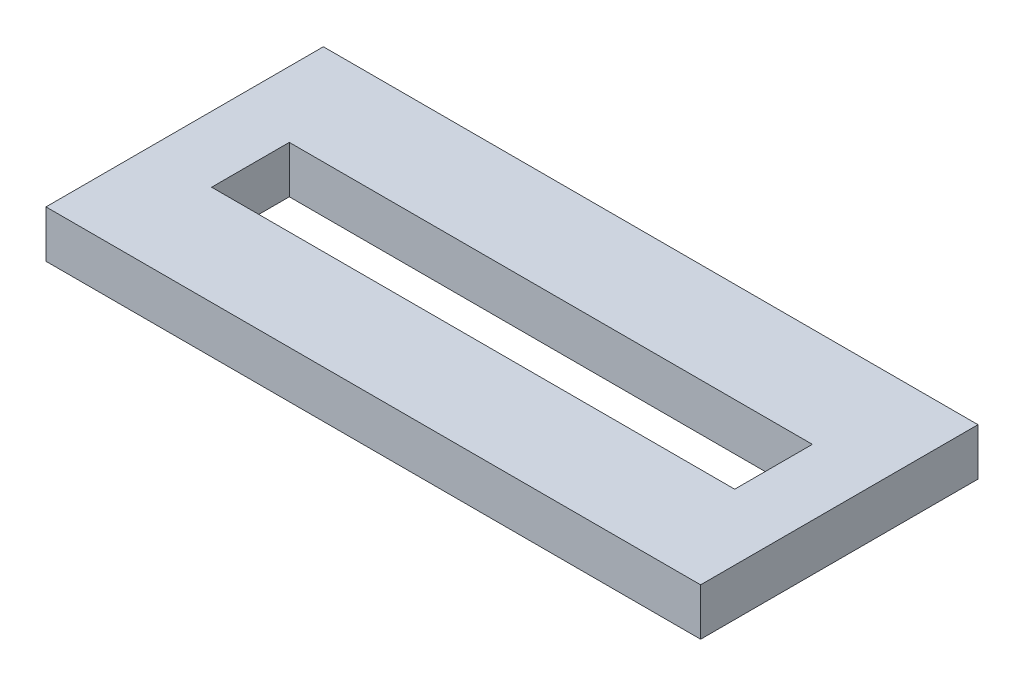
from build123d import *

# Parameters (mm, degrees)
SKETCH2_W           = 59
SKETCH2_H           = 25
BOSS_EXTRUDE1_DEPTH = 4.25
SKETCH3_W           = 47.141785844
SKETCH3_H           = 7
CUT_EXTRUDE1_DEPTH  = 5.25


with BuildPart() as part:
    # Sketch2 → Boss-Extrude1 (new body)
    with BuildSketch(Plane(origin=(0, 0, 0), x_dir=(1, 0, 0), z_dir=(0, 1, 0))):
        with Locations((-6.546875, -2.328125)):
            Rectangle(SKETCH2_W, SKETCH2_H)
    extrude(amount=BOSS_EXTRUDE1_DEPTH)

    # Sketch3 → Cut-Extrude1 (cut, through all)
    with BuildSketch(Plane(origin=(0, 4.25, 0), x_dir=(1, 0, 0), z_dir=(0, 1, 0))):
        with Locations((-6.546875, -2.328125)):
            Rectangle(SKETCH3_W, SKETCH3_H)
    extrude(amount=-CUT_EXTRUDE1_DEPTH, mode=Mode.SUBTRACT)


solid = part.part
